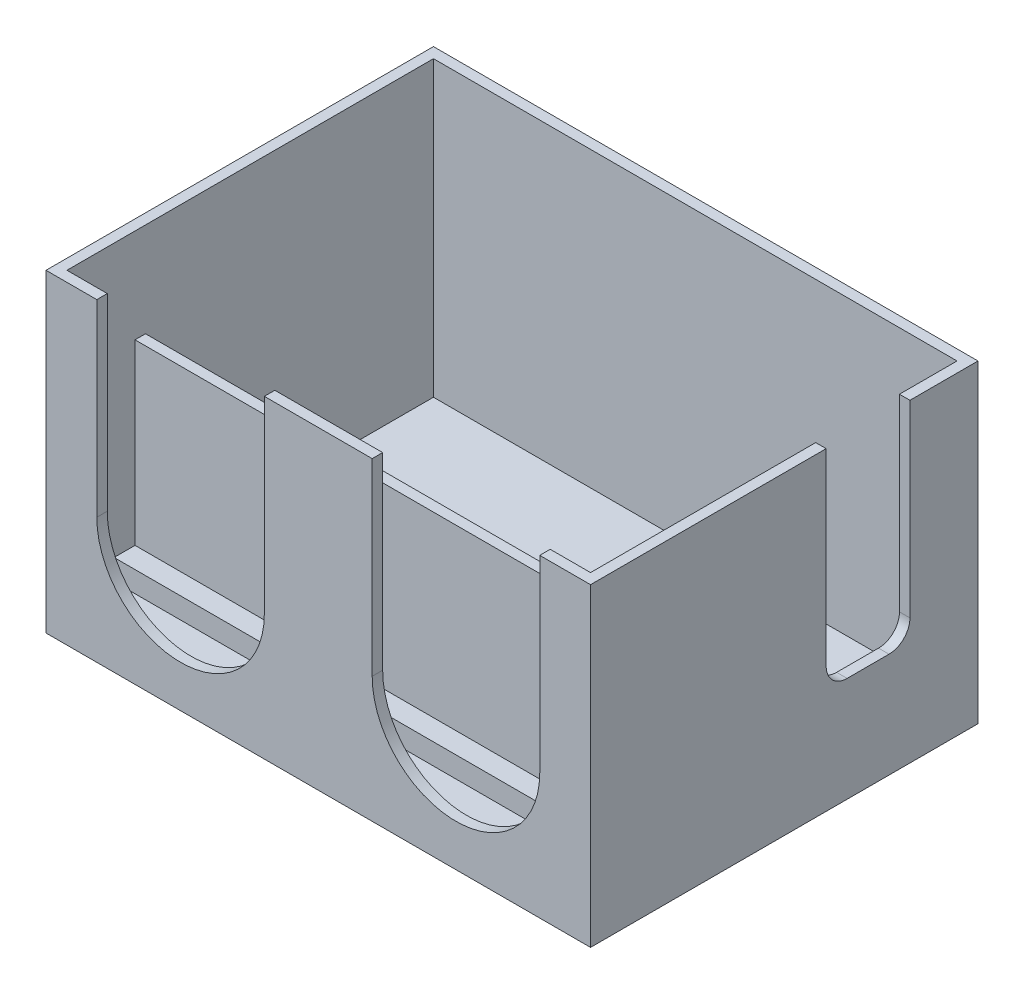
from build123d import *

# Parameters (mm, degrees)
SKETCH1_W           = 52
SKETCH1_H           = 37
SKETCH1_W_2         = 50
SKETCH1_H_2         = 35
BOSS_EXTRUDE1_DEPTH = 30
SKETCH2_W           = 52
SKETCH2_H           = 37
BOSS_EXTRUDE2_DEPTH = 2
CUT_EXTRUDE1_DEPTH  = 2
SKETCH4_W           = 50
SKETCH4_H           = 2
BOSS_EXTRUDE3_DEPTH = 2
CUT_EXTRUDE2_REACH  = 54
SKETCH7_W           = 50
SKETCH7_H           = 1
BOSS_EXTRUDE4_DEPTH = 19


with BuildPart() as part:
    # Sketch1 → Boss-Extrude1 (new body)
    with BuildSketch(Plane(origin=(0, 0, 0), x_dir=(1, 0, 0), z_dir=(0, 1, 0))):
        with Locations((26, 18.5)):
            Rectangle(SKETCH1_W, SKETCH1_H)
        with Locations((26, 18.5)):
            Rectangle(SKETCH1_W_2, SKETCH1_H_2, mode=Mode.SUBTRACT)
    extrude(amount=BOSS_EXTRUDE1_DEPTH)

    # Sketch2 → Boss-Extrude2 (add)
    with BuildSketch(Plane(origin=(0, 0, 0), x_dir=(1, 0, 0), z_dir=(0, 1, 0))):
        with Locations((26, 18.5)):
            Rectangle(SKETCH2_W, SKETCH2_H)
    extrude(amount=BOSS_EXTRUDE2_DEPTH)

    # Sketch3 → Cut-Extrude1 (cut)
    with BuildSketch(Plane.XY):
        with BuildLine():
            Line((4.85, 12), (4.85, 30))
            Line((4.85, 30), (20.85, 30))
            Line((20.85, 30), (20.85, 12))
            ThreePointArc((20.85, 12), (12.85, 4), (4.85, 12))
        make_face()
        with BuildLine():
            Line((31.15, 12), (31.15, 30))
            Line((31.15, 30), (47.15, 30))
            Line((47.15, 30), (47.15, 12))
            ThreePointArc((47.15, 12), (39.15, 4), (31.15, 12))
        make_face()
    extrude(amount=-CUT_EXTRUDE1_DEPTH, mode=Mode.SUBTRACT)

    # Sketch4 → Boss-Extrude3 (add)
    with BuildSketch(Plane(origin=(0, 2, 0), x_dir=(1, 0, 0), z_dir=(0, 1, 0))):
        with Locations((26, 6.5)):
            Rectangle(SKETCH4_W, SKETCH4_H)
        with Locations((26, 14.5)):
            Rectangle(SKETCH4_W, SKETCH4_H)
        with Locations((26, 18.25)):
            Rectangle(SKETCH4_W, SKETCH4_H)
    extrude(amount=BOSS_EXTRUDE3_DEPTH)

    # Sketch5 → Cut-Extrude2 (cut, up to next)
    with BuildSketch(Plane(origin=(52, 0, 0), x_dir=(0, 0, -1), z_dir=(1, 0, 0)), mode=Mode.PRIVATE) as cut_extrude2_sk1:
        with BuildLine():
            Line((30.5, 30), (22.5, 30))
            Line((22.5, 30), (22.5, 12))
            ThreePointArc((22.5, 12), (23.085786438, 10.585786438), (24.5, 10))
            Line((24.5, 10), (28.5, 10))
            ThreePointArc((28.5, 10), (29.914213562, 10.585786438), (30.5, 12))
            Line((30.5, 12), (30.5, 30))
        make_face()
    cut_extrude2_tool1 = extrude(cut_extrude2_sk1.sketch, amount=-CUT_EXTRUDE2_REACH, mode=Mode.PRIVATE) & part.part
    add(cut_extrude2_tool1.solids().sort_by_distance((52, 20.103619, -26.5))[0], mode=Mode.SUBTRACT)

    # Sketch7 → Boss-Extrude4 (add)
    with BuildSketch(Plane(origin=(0, 2, 0), x_dir=(1, 0, 0), z_dir=(0, 1, 0))):
        with Locations((26, 8)):
            Rectangle(SKETCH7_W, SKETCH7_H)
    extrude(amount=BOSS_EXTRUDE4_DEPTH)


solid = part.part
